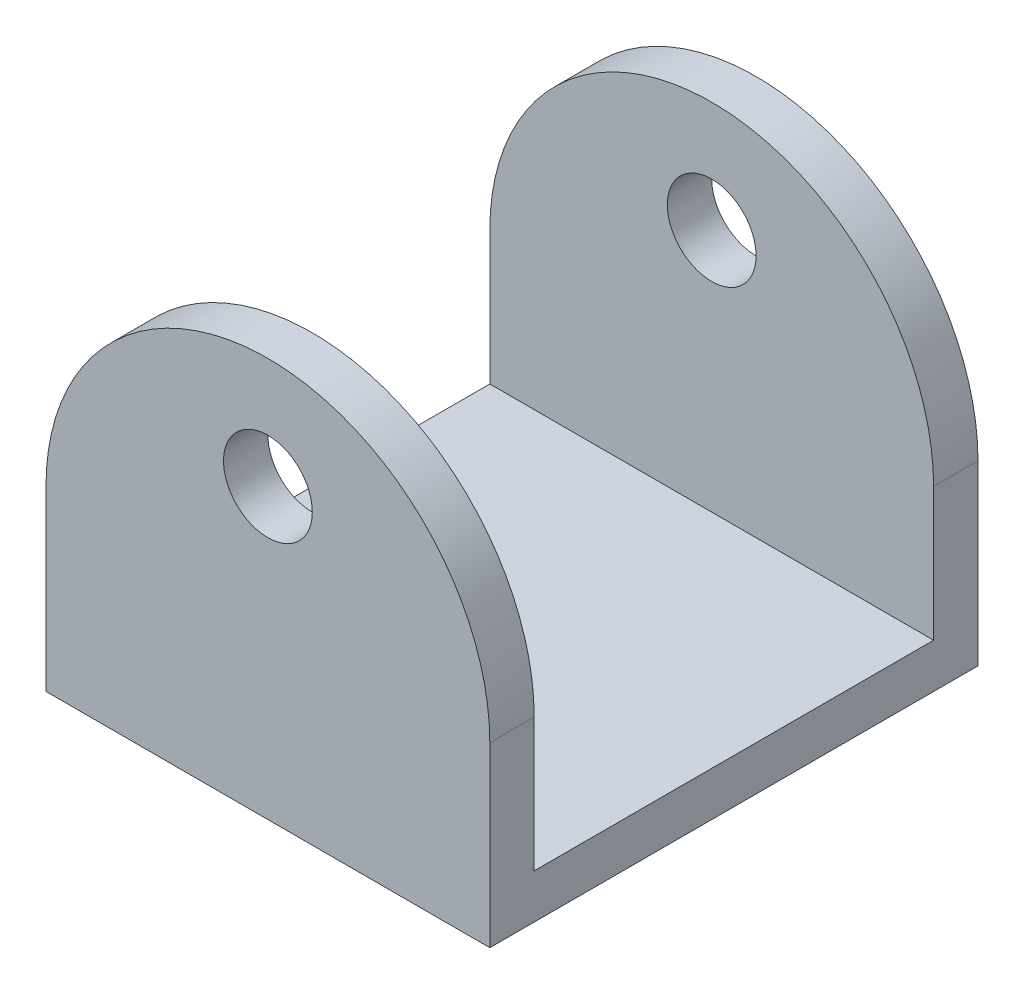
from build123d import *

# Parameters (mm, degrees)
SKETCH1_R               = 6.35
BOSS_EXTRUDE1_DEPTH     = 69.85
SKETCH2_W               = 57.15
SKETCH2_H               = 54.522023849
CUT_EXTRUDE1_DEPTH      = 1
CUT_EXTRUDE1_DEPTH_BACK = 64.5


with BuildPart() as part:
    # Sketch1 → Boss-Extrude1 (new body)
    with BuildSketch(Plane.XY):
        with BuildLine():
            Line((-22.713461538, -22.102884615), (-22.713461538, -47.502884615))
            Line((-22.713461538, -47.502884615), (40.786538462, -47.502884615))
            Line((40.786538462, -47.502884615), (40.786538462, -22.102884615))
            ThreePointArc((40.786538462, -22.102884615), (9.036538462, 9.647115385), (-22.713461538, -22.102884615))
        make_face()
        with Locations((9.036538462, -6.227884615)):
            Circle(SKETCH1_R, mode=Mode.SUBTRACT)
    extrude(amount=BOSS_EXTRUDE1_DEPTH)

    # Sketch2 → Cut-Extrude1 (cut, two sides)
    with BuildSketch(Plane.ZY.offset(22.713461538)) as cut_extrude1_sk:
        with Locations((34.925, -13.891872691)):
            Rectangle(SKETCH2_W, SKETCH2_H)
    extrude(amount=CUT_EXTRUDE1_DEPTH, mode=Mode.SUBTRACT)
    extrude(cut_extrude1_sk.sketch, amount=-CUT_EXTRUDE1_DEPTH_BACK, mode=Mode.SUBTRACT)


solid = part.part
